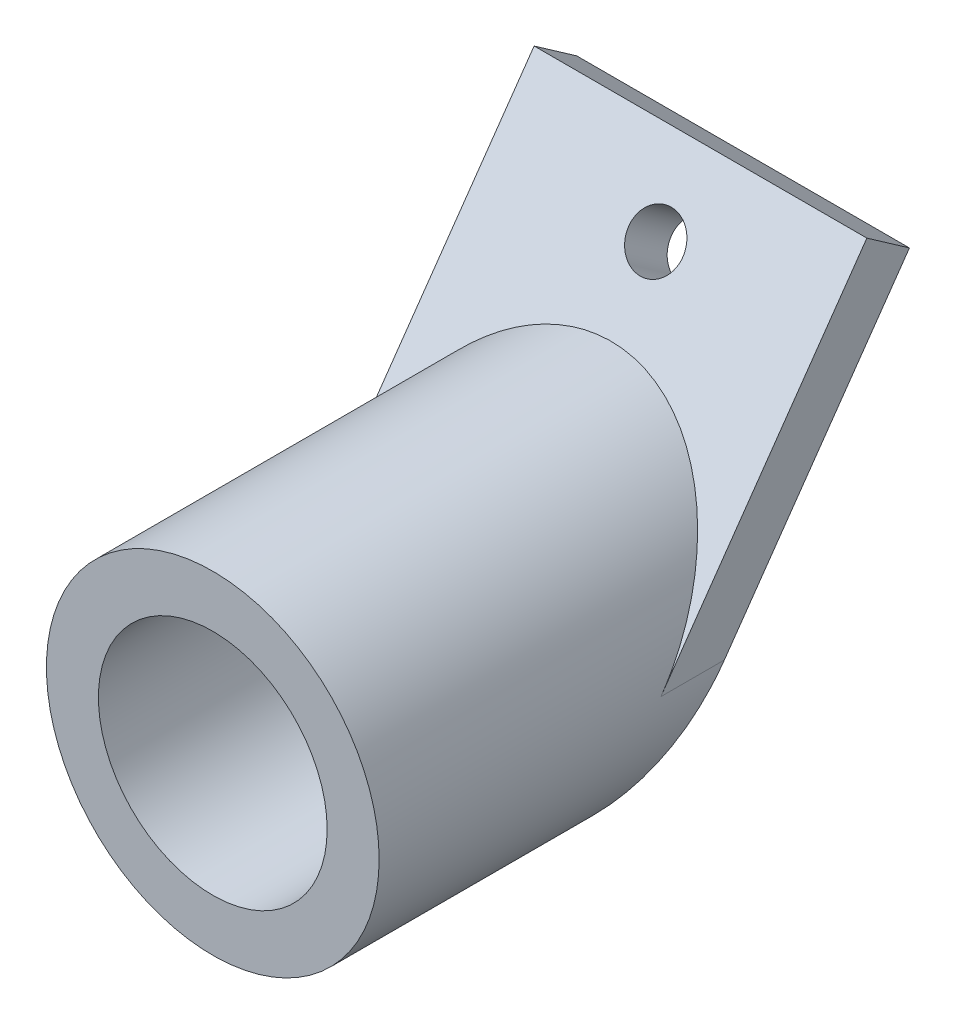
from build123d import *

# Parameters (mm, degrees)
SKETCH1_R                = 16
SKETCH1_R_2              = 11
BOSS_EXTRUDE1_DEPTH      = 20
SKETCH2_R                = 16
BOSS_EXTRUDE2_DEPTH      = 2
BOSS_EXTRUDE3_DEPTH      = 16
BOSS_EXTRUDE3_DEPTH_BACK = 16
CUT_EXTRUDE1_DEPTH       = 30.002175046
BOSS_EXTRUDE4_REACH      = 31.002
SKETCH5_R                = 16
SKETCH6_R                = 2.6
CUT_EXTRUDE3_DEPTH       = 29.757190977


with BuildPart() as part:
    # Sketch1 → Boss-Extrude1 (new body)
    with BuildSketch(Plane.XY):
        Circle(SKETCH1_R)
        Circle(SKETCH1_R_2, mode=Mode.SUBTRACT)
    extrude(amount=BOSS_EXTRUDE1_DEPTH)

    # Sketch2 → Boss-Extrude2 (add)
    with BuildSketch(Plane(origin=(0, 0, 0), x_dir=(-1, 0, 0), z_dir=(0, 0, -1))):
        Circle(SKETCH2_R)
    extrude(amount=BOSS_EXTRUDE2_DEPTH)

    # Sketch3 → Boss-Extrude3 (add, two sides)
    with BuildSketch(Plane(origin=(0, 0, 0), x_dir=(0, 0, -1), z_dir=(1, 0, 0))) as boss_extrude3_sk:
        Polygon((31.002175046, 25.419398483), (26.906414824, 28.287280664), (18.302768279, 16), (2, -7.282766022), (2, -16), align=None)
    extrude(amount=BOSS_EXTRUDE3_DEPTH)
    extrude(boss_extrude3_sk.sketch, amount=-BOSS_EXTRUDE3_DEPTH_BACK)

    # Sketch4 → Cut-Extrude1 (cut, through all)
    with BuildSketch(Plane(origin=(0, 0, -2), x_dir=(-1, 0, 0), z_dir=(0, 0, -1))):
        with BuildLine():
            Line((34.266518051, 0), (16, 0))
            ThreePointArc((16, 0), (15.555436181, -3.745451268), (14.24644935, -7.282766022))
            ThreePointArc((14.24644935, -7.282766022), (0, -16), (-14.24644935, -7.282766022))
            ThreePointArc((-14.24644935, -7.282766022), (-15.555436181, -3.745451268), (-16, 0))
            Line((-16, 0), (-34.430612934, 0))
            Line((-34.430612934, 0), (-36.46308972, -20.488677285))
            Line((-36.46308972, -20.488677285), (32.179774964, -27.298049462))
            Line((32.179774964, -27.298049462), (34.266518051, 0))
        make_face()
    extrude(amount=CUT_EXTRUDE1_DEPTH, mode=Mode.SUBTRACT)

    # Sketch5 → Boss-Extrude4 (add, up to next)
    with BuildSketch(Plane(origin=(0, 0, -2), x_dir=(-1, 0, 0), z_dir=(0, 0, -1)), mode=Mode.PRIVATE) as boss_extrude4_sk1:
        Circle(SKETCH5_R)
    boss_extrude4_tool1 = extrude(boss_extrude4_sk1.sketch, amount=BOSS_EXTRUDE4_REACH, mode=Mode.PRIVATE) - part.part
    add(boss_extrude4_tool1.solids().sort_by_distance((0, 0, -2))[0])

    # Sketch6 → Cut-Extrude3 (cut, through all)
    with BuildSketch(Plane(origin=(0, -3.335649292, -4.763800888), x_dir=(1, 0, 0), z_dir=(0, 0.573576436, 0.819152044))):
        with Locations((0, 31.104469313)):
            Circle(SKETCH6_R)
    extrude(amount=-CUT_EXTRUDE3_DEPTH, mode=Mode.SUBTRACT)


solid = part.part
